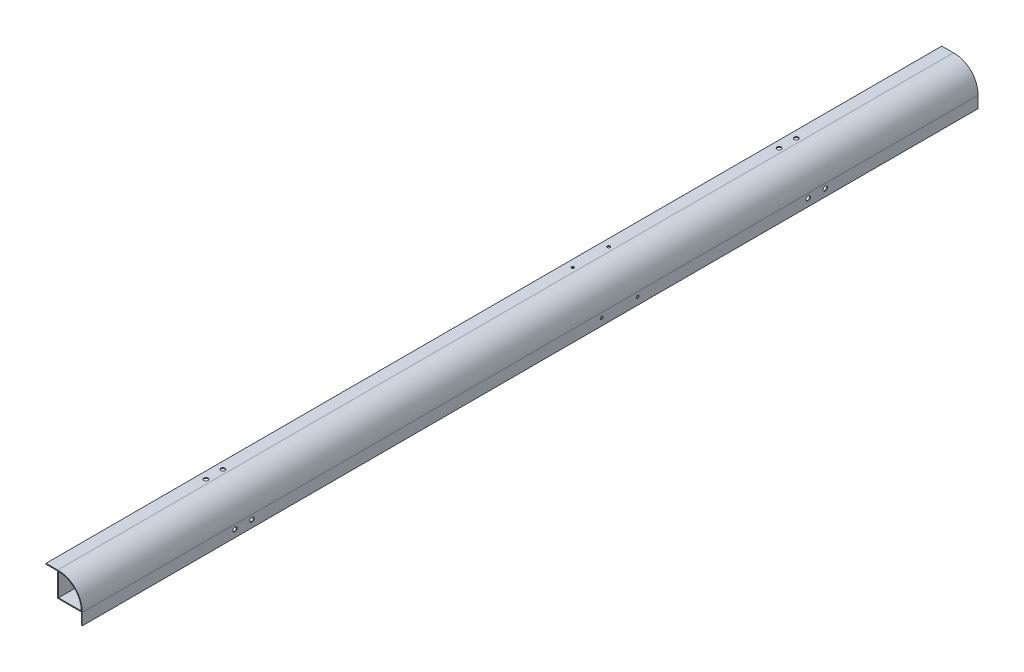
from build123d import *

# Parameters (mm, degrees)
CROQUIS1_W              = 13
CROQUIS1_H              = 1
CROQUIS1_W_2            = 1
CROQUIS1_H_2            = 13
SALIENTE_EXTRUIR1_DEPTH = 500
CROQUIS2_R              = 2.38125
CROQUIS2_R_2            = 1.5
CORTAR_EXTRUIR1_DEPTH   = 10
CROQUIS3_R              = 2.38125
CROQUIS3_R_2            = 1.5
CORTAR_EXTRUIR2_DEPTH   = 10


with BuildPart() as part:
    # Croquis1 → Saliente-Extruir1 (new body, symmetric)
    with BuildSketch(Plane.XY):
        with BuildLine():
            ThreePointArc((-13.7, 13.681053808), (5.967619023, 5.967619023), (13.681053808, -13.7))
            Line((13.681053808, -13.7), (-13.7, -13.7))
            Line((-13.7, -13.7), (-13.7, 13.681053808))
        make_face()
        with BuildLine():
            Line((-12.7, -12.7), (-12.7, 12.7))
            ThreePointArc((-12.7, 12.7), (5.260512242, 5.260512242), (12.7, -12.7))
            Line((12.7, -12.7), (-12.7, -12.7))
        make_face(mode=Mode.SUBTRACT)
        with Locations((-20.2, 13.181053808)):
            Rectangle(CROQUIS1_W, CROQUIS1_H)
        with Locations((13.181053808, -20.2)):
            Rectangle(CROQUIS1_W_2, CROQUIS1_H_2)
    extrude(amount=SALIENTE_EXTRUIR1_DEPTH, both=True)

    # Croquis2 → Cortar-Extruir1 (cut)
    with BuildSketch(Plane(origin=(13.681053808, 0, 0), x_dir=(0, 0, -1), z_dir=(1, 0, 0))):
        with Locations((310.5, -18.7)):
            Circle(CROQUIS2_R)
        with Locations((329.5, -18.7)):
            Circle(CROQUIS2_R)
        with Locations((-329.5, -18.7)):
            Circle(CROQUIS2_R)
        with Locations((-310.5, -18.7)):
            Circle(CROQUIS2_R)
        with Locations((120, -18.7)):
            Circle(CROQUIS2_R_2)
        with Locations((80, -18.7)):
            Circle(CROQUIS2_R_2)
    extrude(amount=-CORTAR_EXTRUIR1_DEPTH, mode=Mode.SUBTRACT)

    # Croquis3 → Cortar-Extruir2 (cut)
    with BuildSketch(Plane(origin=(0, 13.681053808, 0), x_dir=(1, 0, 0), z_dir=(0, 1, 0))):
        with Locations((-18.7, 329.5)):
            Circle(CROQUIS3_R)
        with Locations((-18.7, 310.5)):
            Circle(CROQUIS3_R)
        with Locations((-18.7, -310.5)):
            Circle(CROQUIS3_R)
        with Locations((-18.7, -329.5)):
            Circle(CROQUIS3_R)
        with Locations((-18.7, 120)):
            Circle(CROQUIS3_R_2)
        with Locations((-18.7, 80)):
            Circle(CROQUIS3_R_2)
    extrude(amount=-CORTAR_EXTRUIR2_DEPTH, mode=Mode.SUBTRACT)


solid = part.part
